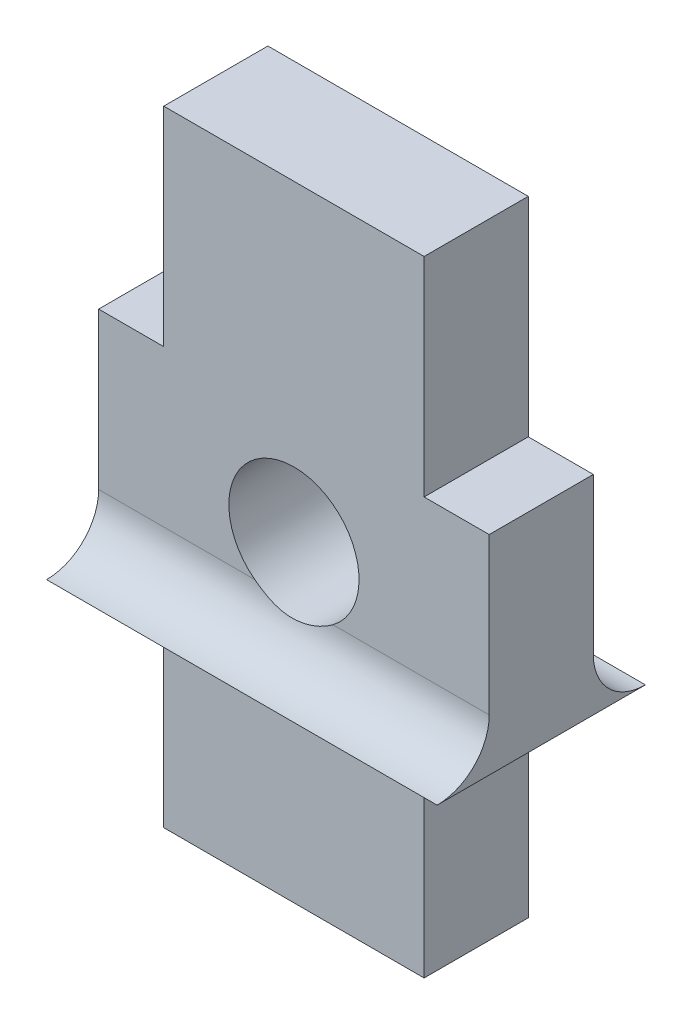
from build123d import *

# Parameters (mm, degrees)
SKETCH1_R               = 1.25
BOSS_EXTRUDE1_DEPTH     = 2
BOSS_EXTRUDE2_DEPTH     = 7.5
SKETCH3_R               = 1.25
CUT_EXTRUDE1_DEPTH      = 2
CUT_EXTRUDE1_DEPTH_BACK = 4


with BuildPart() as part:
    # Sketch1 → Boss-Extrude1 (new body)
    with BuildSketch(Plane.XY):
        Polygon((1952.176808721, 1466.884115951), (1957.176808721, 1466.884115951), (1957.176808721, 1462.884115951), (1958.426808721, 1462.884115951), (1958.426808721, 1458.884115951), (1957.176808721, 1458.884115951), (1957.176808721, 1454.884115951), (1952.176808721, 1454.884115951), (1952.176808721, 1458.884115951), (1950.926808721, 1458.884115951), (1950.926808721, 1462.884115951), (1952.176808721, 1462.884115951), align=None)
        with Locations((1954.676808721, 1460.884115951)):
            Circle(SKETCH1_R, mode=Mode.SUBTRACT)
    extrude(amount=BOSS_EXTRUDE1_DEPTH)

    # Sketch2 → Boss-Extrude2 (add)
    with BuildSketch(Plane.ZY.offset(-1950.926808721)):
        with BuildLine():
            Line((2, 1458.884115951), (2, 1459.884115951))
            ThreePointArc((2, 1459.884115951), (2.292893219, 1459.17700917), (3, 1458.884115951))
            Line((3, 1458.884115951), (2, 1458.884115951))
        make_face()
        with BuildLine():
            Line((0, 1458.884115951), (-1, 1458.884115951))
            ThreePointArc((-1, 1458.884115951), (-0.292893219, 1459.17700917), (0, 1459.884115951))
            Line((0, 1459.884115951), (0, 1458.884115951))
        make_face()
    extrude(amount=-BOSS_EXTRUDE2_DEPTH)

    # Sketch3 → Cut-Extrude1 (cut, two sides)
    with BuildSketch(Plane.XY.offset(2)) as cut_extrude1_sk:
        with Locations((1954.676808721, 1460.884115951)):
            Circle(SKETCH3_R)
    extrude(amount=CUT_EXTRUDE1_DEPTH, mode=Mode.SUBTRACT)
    extrude(cut_extrude1_sk.sketch, amount=-CUT_EXTRUDE1_DEPTH_BACK, mode=Mode.SUBTRACT)


solid = part.part
